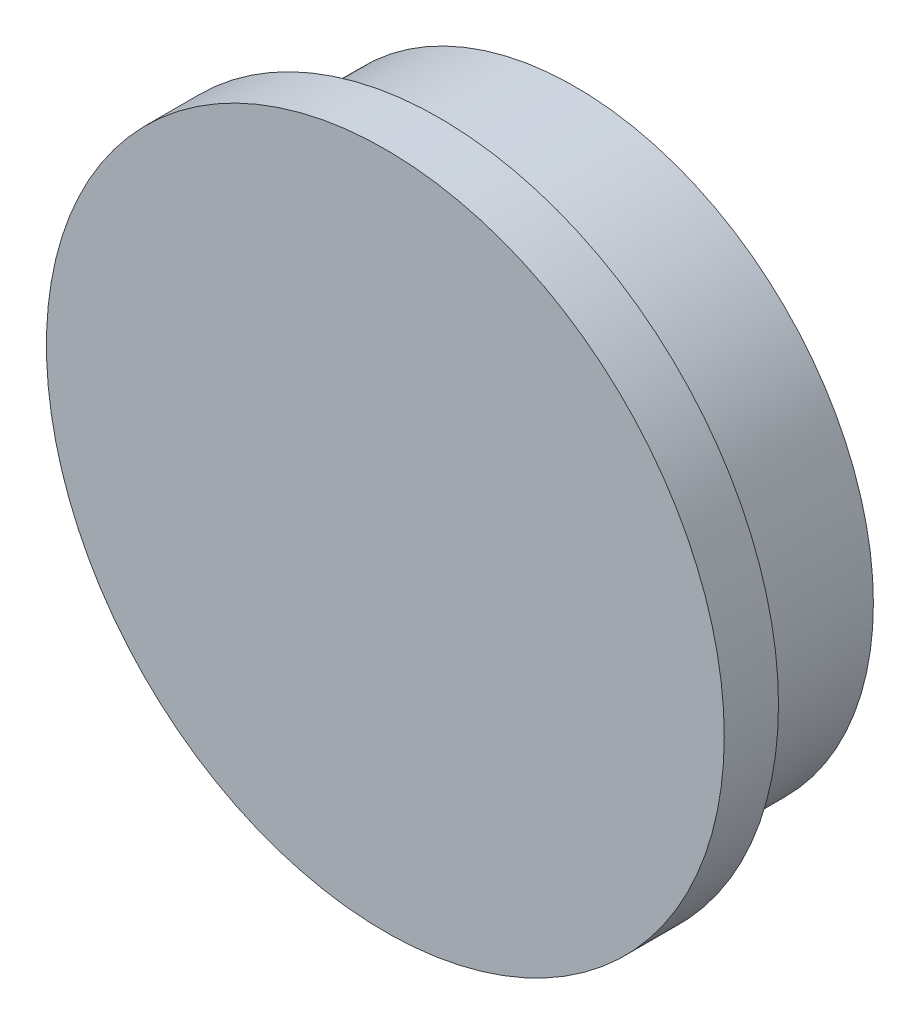
from build123d import *

# Parameters (mm, degrees)
SKETCH1_R           = 5.588
BOSS_EXTRUDE1_DEPTH = 2.54
SKETCH2_R           = 6.35
BOSS_EXTRUDE2_DEPTH = 1.016


with BuildPart() as part:
    # Sketch1 → Boss-Extrude1 (new body)
    with BuildSketch(Plane.XY):
        with Locations((35.4584, -19.288769968)):
            Circle(SKETCH1_R)
    extrude(amount=-BOSS_EXTRUDE1_DEPTH)

    # Sketch2 → Boss-Extrude2 (add)
    with BuildSketch(Plane.XY):
        with Locations((35.4584, -19.288769968)):
            Circle(SKETCH2_R)
    extrude(amount=BOSS_EXTRUDE2_DEPTH)


solid = part.part
